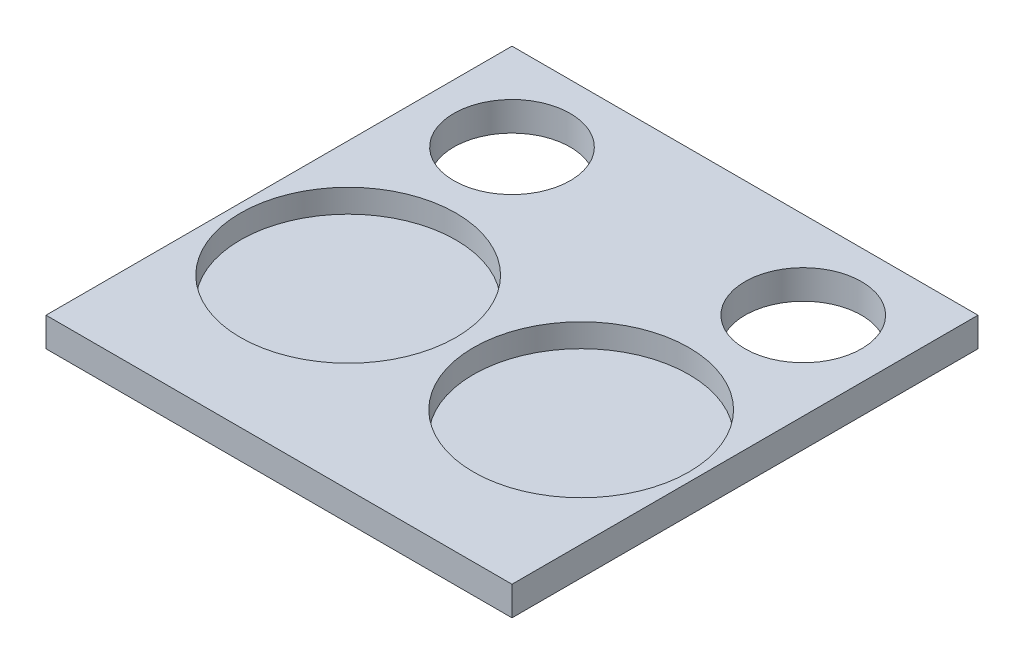
from build123d import *

# Parameters (mm, degrees)
SKETCH1_W           = 101.6
SKETCH1_H           = 101.6
SKETCH1_R           = 12.7
BOSS_EXTRUDE1_DEPTH = 3.175
SKETCH2_R           = 23.495
CUT_EXTRUDE1_DEPTH  = 5.08


with BuildPart() as part:
    # Sketch1 → Boss-Extrude1 (new body, symmetric)
    with BuildSketch(Plane(origin=(0, 0, 0), x_dir=(1, 0, 0), z_dir=(0, 1, 0))):
        Rectangle(SKETCH1_W, SKETCH1_H)
        with Locations((-31.75, 31.75)):
            Circle(SKETCH1_R, mode=Mode.SUBTRACT)
        with Locations((31.75, 31.75)):
            Circle(SKETCH1_R, mode=Mode.SUBTRACT)
    extrude(amount=BOSS_EXTRUDE1_DEPTH, both=True)

    # Sketch2 → Cut-Extrude1 (cut)
    with BuildSketch(Plane(origin=(0, 3.175, 0), x_dir=(1, 0, 0), z_dir=(0, 1, 0))):
        with Locations((-25.4, -10.318450471)):
            Circle(SKETCH2_R)
        with Locations((25.4, -10.318450471)):
            Circle(SKETCH2_R)
    extrude(amount=-CUT_EXTRUDE1_DEPTH, mode=Mode.SUBTRACT)


solid = part.part
